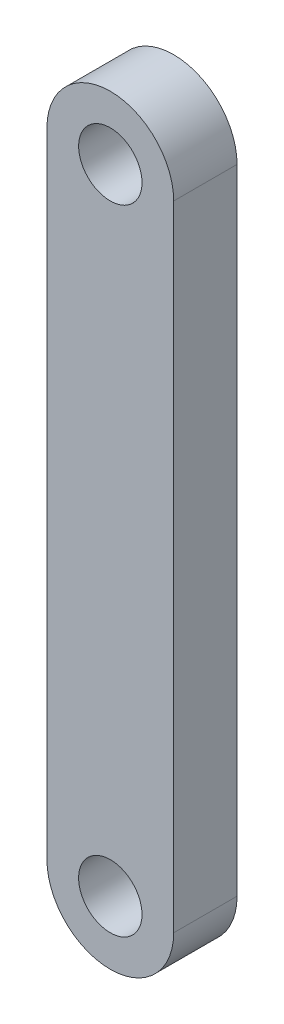
from build123d import *

# Parameters (mm, degrees)
SKETCH1_R           = 3.175
BOSS_EXTRUDE1_DEPTH = 6.35


with BuildPart() as part:
    # Sketch1 → Boss-Extrude1 (new body)
    with BuildSketch(Plane.XY):
        with BuildLine():
            Line((-6.35, 63.5), (-6.35, 0))
            ThreePointArc((-6.35, 0), (0, -6.35), (6.35, 0))
            Line((6.35, 0), (6.35, 63.5))
            ThreePointArc((6.35, 63.5), (0, 69.85), (-6.35, 63.5))
        make_face()
        Circle(SKETCH1_R, mode=Mode.SUBTRACT)
        with Locations((0, 63.5)):
            Circle(SKETCH1_R, mode=Mode.SUBTRACT)
    extrude(amount=BOSS_EXTRUDE1_DEPTH)


solid = part.part
